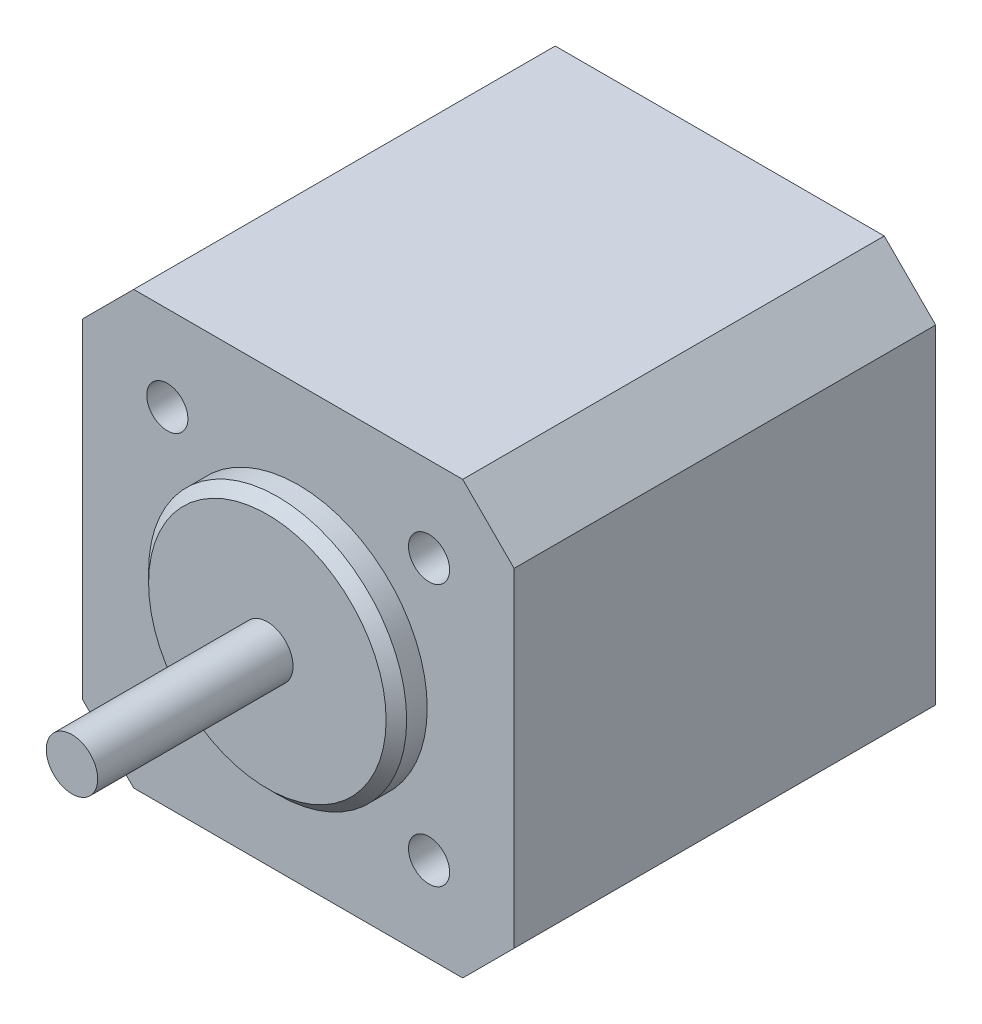
from build123d import *

# Parameters (mm, degrees)
CROQUIS1_R              = 2
SALIENTE_EXTRUIR1_DEPTH = 41
CROQUIS2_R              = 12.55
SALIENTE_EXTRUIR2_DEPTH = 3
CROQUIS3_R              = 2.5
SALIENTE_EXTRUIR3_DEPTH = 19
CHAFL_N1_SIZE           = 1


with BuildPart() as part:
    # Croquis1 → Saliente-Extruir1 (new body)
    with BuildSketch(Plane.XY):
        Polygon((-21, 16), (-16, 21), (16, 21), (21, 16), (21, -16), (16, -21), (-16, -21), (-21, -16), align=None)
        with Locations((12.727922061, 12.727922061)):
            Circle(CROQUIS1_R, mode=Mode.SUBTRACT)
        with Locations((12.727922061, -12.727922061)):
            Circle(CROQUIS1_R, mode=Mode.SUBTRACT)
        with Locations((-12.727922061, -12.727922061)):
            Circle(CROQUIS1_R, mode=Mode.SUBTRACT)
        with Locations((-12.727922061, 12.727922061)):
            Circle(CROQUIS1_R, mode=Mode.SUBTRACT)
    extrude(amount=SALIENTE_EXTRUIR1_DEPTH)

    # Croquis2 → Saliente-Extruir2 (add)
    with BuildSketch(Plane.XY.offset(41)):
        Circle(CROQUIS2_R)
    extrude(amount=SALIENTE_EXTRUIR2_DEPTH)

    # Croquis3 → Saliente-Extruir3 (add)
    with BuildSketch(Plane.XY.offset(44)):
        Circle(CROQUIS3_R)
    extrude(amount=SALIENTE_EXTRUIR3_DEPTH)

    # Chaflán1
    chafl_n1_edges = [part.edges().sort_by_distance(p)[0] for p in [
        (-12.55, 0, 44),
    ]]
    chamfer(chafl_n1_edges, length=CHAFL_N1_SIZE)


solid = part.part
